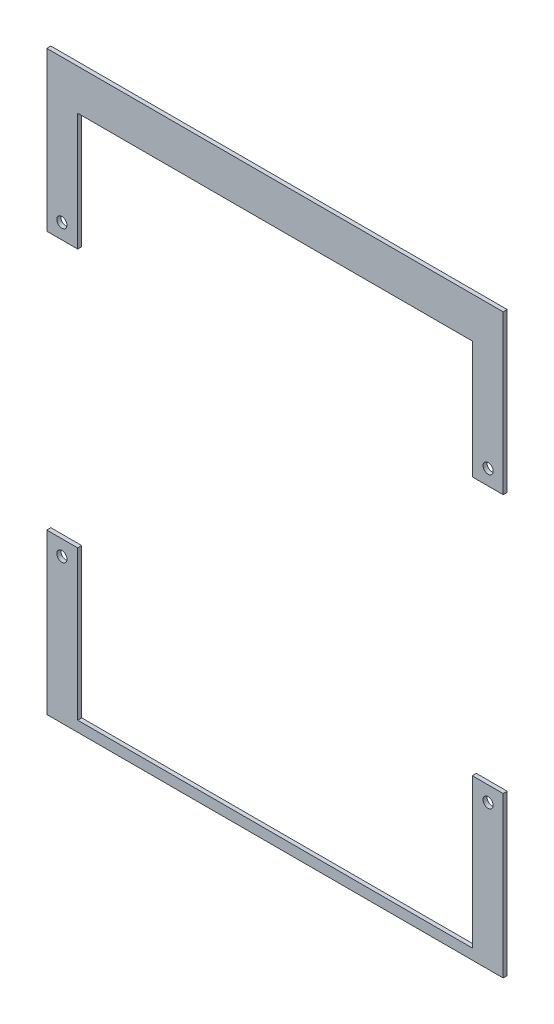
from build123d import *

# Parameters (mm, degrees)
SKETCH1_R               = 2
REPEATING_FRAME_DEPTH   = 1.5875
REPEATING_FRAME_2_DEPTH = 1.5875


with BuildPart() as part:
    # Sketch1 → Repeating Frame (new body)
    with BuildSketch(Plane.XY):
        Polygon((-77.5, 103.25), (0, 103.25), (0, 119.25), (-89.6514, 119.25), (-89.6514, 57.03), (-77.5, 57.03), align=None)
        with Locations((-83.72, 63.03)):
            Circle(SKETCH1_R, mode=Mode.SUBTRACT)
    repeating_frame = extrude(amount=REPEATING_FRAME_DEPTH)


with BuildPart() as body_2:
    # Sketch1 → Repeating Frame 2 (new body)
    with BuildSketch(Plane.XY):
        Polygon((-89.6514, -107.38), (0, -107.38), (0, -103.25), (-77.5, -103.25), (-77.5, -44.6224), (-89.6514, -44.6224), align=None)
        with Locations((-83.72, -50.6224)):
            Circle(SKETCH1_R, mode=Mode.SUBTRACT)
    repeating_frame_2 = extrude(amount=REPEATING_FRAME_2_DEPTH)


with BuildPart() as part_1:
    add(part.part)

    add(body_2.part)  # Mirror1 merges body 2
    # Mirror1: Repeating Frame, Repeating Frame 2 across plane
    add(repeating_frame.mirror(Plane(origin=(0, 0, 0), x_dir=(0, 0, 1), z_dir=(1, 0, 0))))
    add(repeating_frame_2.mirror(Plane(origin=(0, 0, 0), x_dir=(0, 0, 1), z_dir=(1, 0, 0))))


solid = part_1.part
